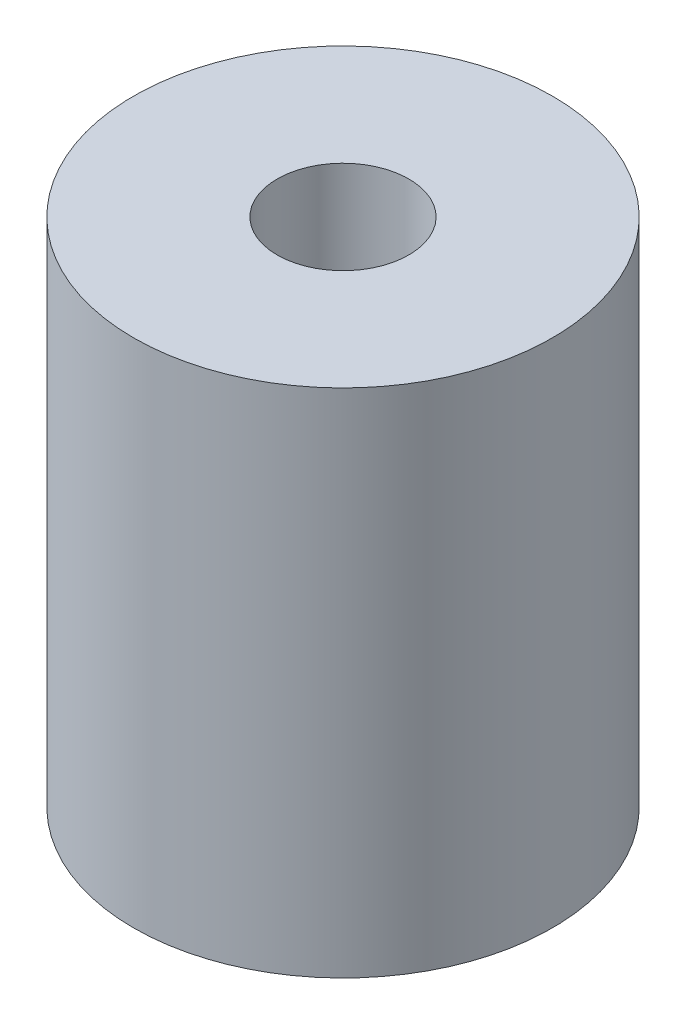
from build123d import *

# Parameters (mm, degrees)
SKETCH2_R             = 3.9751
BOSS_EXTRUDE1_DEPTH   = 4.85
M3X0_5_TAPPED_HOLE1_D = 2.5


with BuildPart() as part:
    # Sketch2 → Boss-Extrude1 (new body, symmetric)
    with BuildSketch(Plane(origin=(0, 0, 0), x_dir=(1, 0, 0), z_dir=(0, 1, 0))):
        Circle(SKETCH2_R)
    extrude(amount=BOSS_EXTRUDE1_DEPTH, both=True)

    # M3x0.5 Tapped Hole1 (through all)
    with Locations(Plane(origin=(0, 4.85, 0), x_dir=(1, 0, 0), z_dir=(0, 1, 0))):
        with Locations((0, 0)):
            Hole(M3X0_5_TAPPED_HOLE1_D / 2)


solid = part.part
